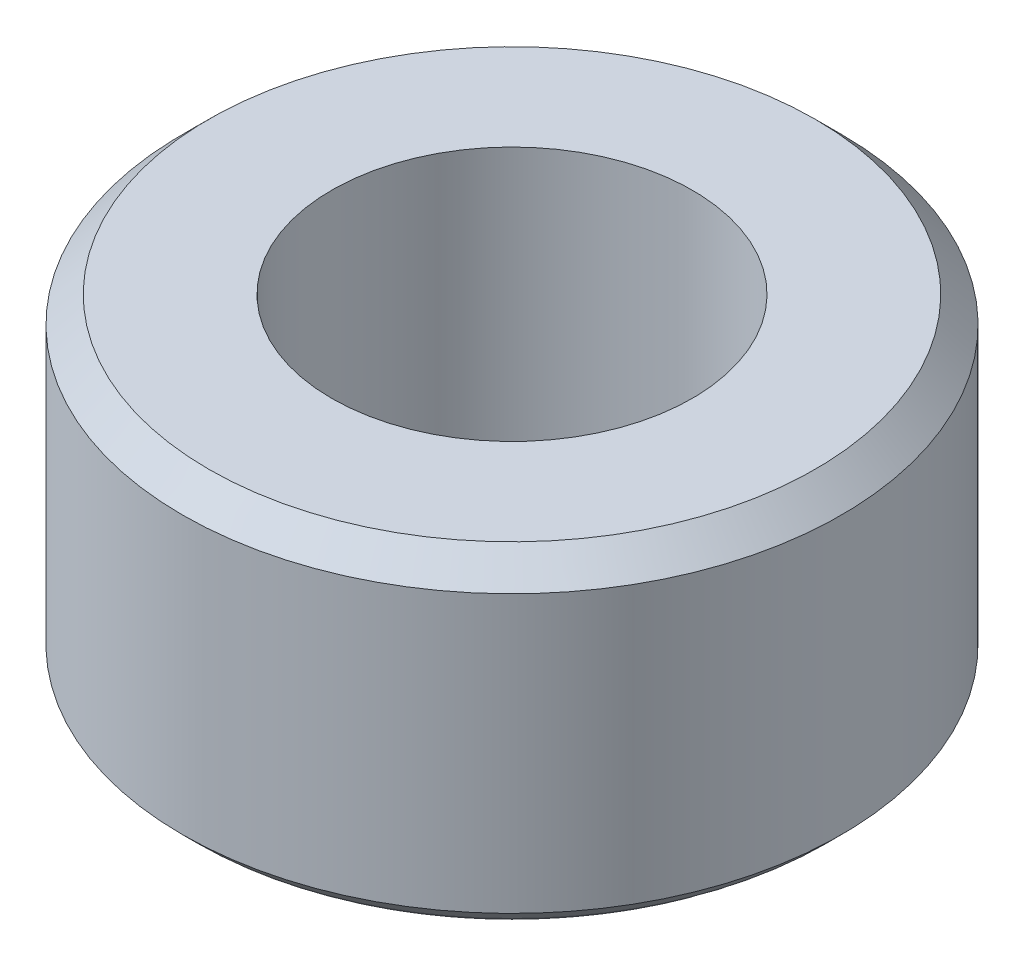
from build123d import *

# Parameters (mm, degrees)
SKETCH1_R                   = 6.35
BOSS_EXTRUDE1_DEPTH         = 6.35
F_1_4_0_25_DIAMETER_HOLE1_D = 6.95000007
CHAMFER1_SIZE               = 0.508
FILLET1_R                   = 0.76


with BuildPart() as part:
    # Sketch1 → Boss-Extrude1 (new body)
    with BuildSketch(Plane(origin=(0, 0, 0), x_dir=(1, 0, 0), z_dir=(0, 1, 0))):
        Circle(SKETCH1_R)
    extrude(amount=BOSS_EXTRUDE1_DEPTH)

    # 1/4 (0.25) Diameter Hole1 (through all)
    with Locations(Plane(origin=(0, 6.35, 0), x_dir=(1, 0, 0), z_dir=(0, 1, 0))):
        with Locations((0, 0)):
            Hole(F_1_4_0_25_DIAMETER_HOLE1_D / 2)

    # Chamfer1
    chamfer1_edges = [part.edges().sort_by_distance(p)[0] for p in [
        (-6.35, 0, 0),
        (-6.35, 6.35, 0),
    ]]
    chamfer(chamfer1_edges, length=CHAMFER1_SIZE)

    # Fillet1
    fillet1_edges = [part.edges().sort_by_distance(p)[0] for p in [
        (-5.842, 0, 0),
    ]]
    fillet(fillet1_edges, radius=FILLET1_R)


solid = part.part
